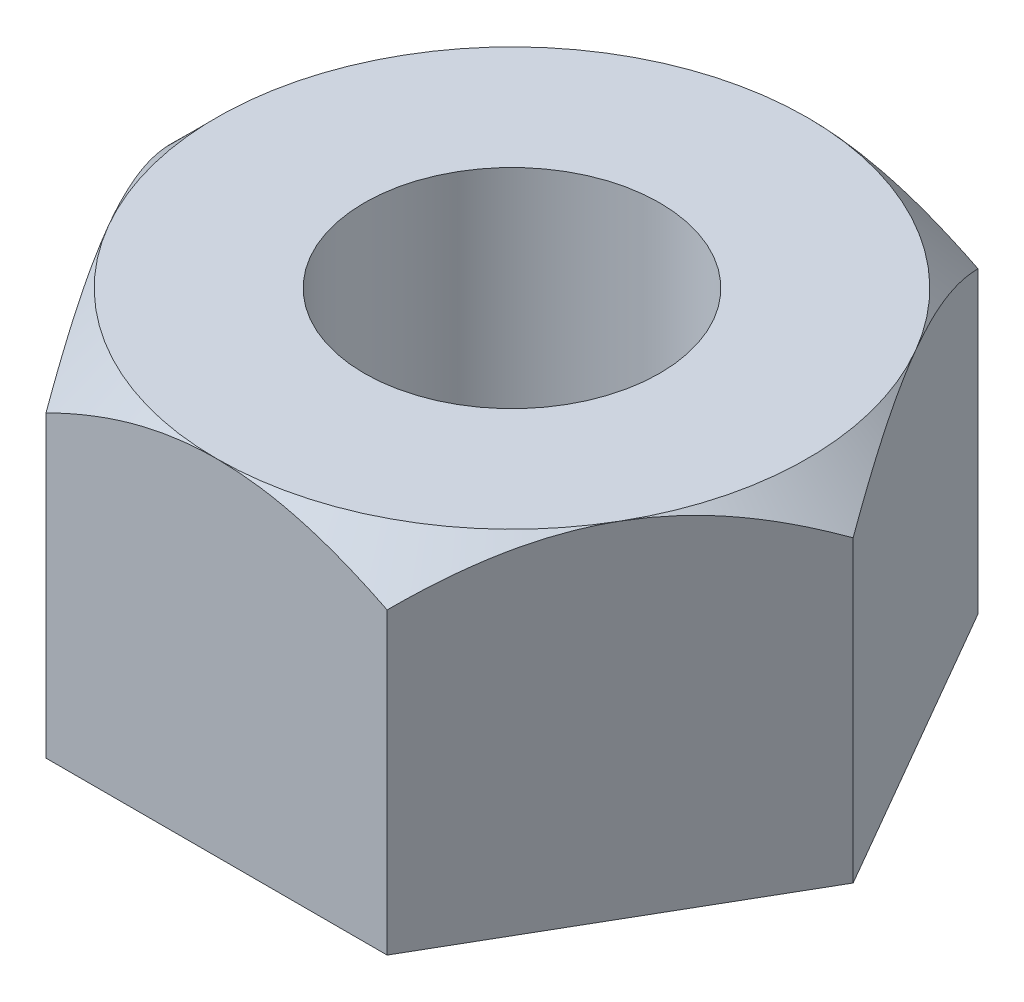
from build123d import *

# Parameters (mm, degrees)
SKETCH1_R           = 15
BOSS_EXTRUDE1_DEPTH = 35
SKETCH2_OUTSIDE_W   = 110.904
SKETCH2_OUTSIDE_H   = 101.622
SKETCH2_OUTSIDE_R   = 30
CUT_EXTRUDE1_DEPTH  = 10
CUT_EXTRUDE1_TAPER  = 45


with BuildPart() as part:
    # Sketch1 → Boss-Extrude1 (new body)
    with BuildSketch(Plane(origin=(0, 0, 0), x_dir=(1, 0, 0), z_dir=(0, 1, 0))):
        Polygon((34.641016151, 0), (17.320508076, 30), (-17.320508076, 30), (-34.641016151, 0), (-17.320508076, -30), (17.320508076, -30), align=None)
        Circle(SKETCH1_R, mode=Mode.SUBTRACT)
    extrude(amount=BOSS_EXTRUDE1_DEPTH)

    # Sketch2 outside → Cut-Extrude1 (cut)
    with BuildSketch(Plane(origin=(0, 35, 0), x_dir=(1, 0, 0), z_dir=(0, 1, 0))):
        Rectangle(SKETCH2_OUTSIDE_W, SKETCH2_OUTSIDE_H)
        Circle(SKETCH2_OUTSIDE_R, mode=Mode.SUBTRACT)
    extrude(amount=-CUT_EXTRUDE1_DEPTH, taper=CUT_EXTRUDE1_TAPER, mode=Mode.SUBTRACT)


solid = part.part
